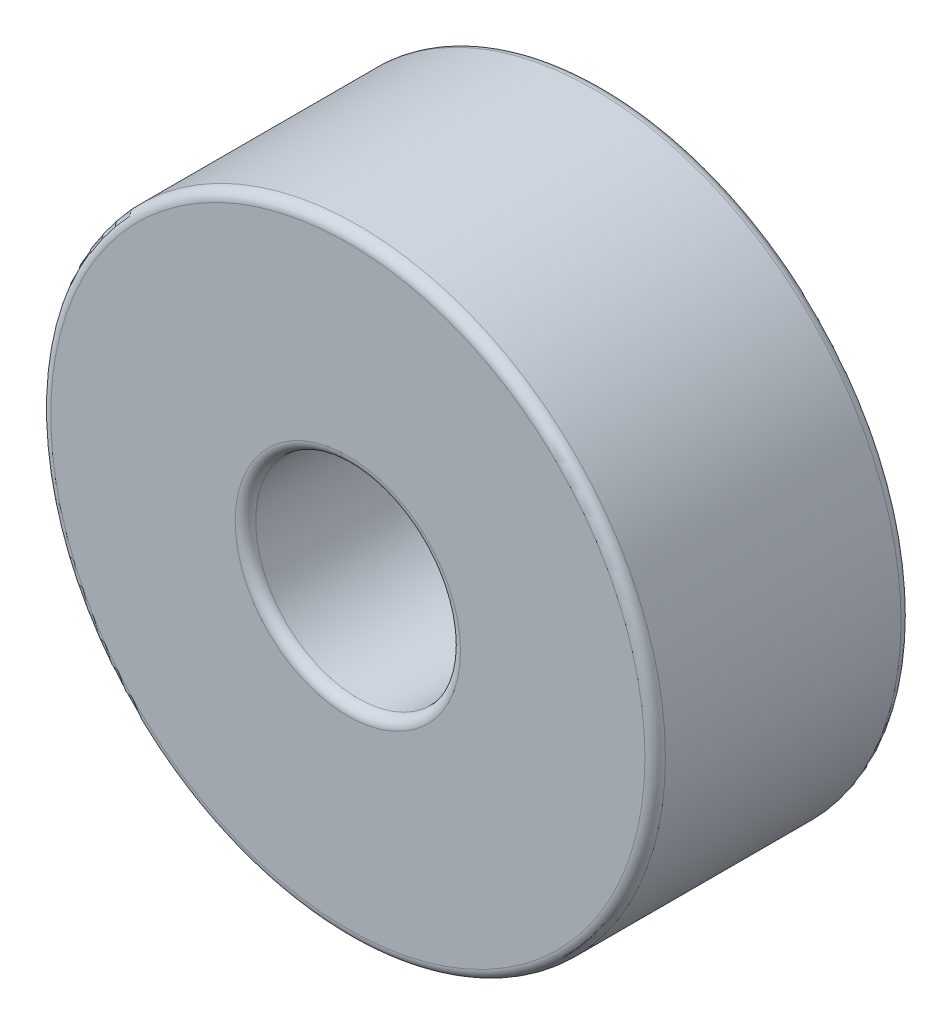
from build123d import *

# Parameters (mm, degrees)
SKETCH1_R           = 3
SKETCH1_R_2         = 1
BOSS_EXTRUDE1_DEPTH = 2.5
FILLET1_R           = 0.1
FILLET2_R           = 0.1


with BuildPart() as part:
    # Sketch1 → Boss-Extrude1 (new body)
    with BuildSketch(Plane.XY):
        Circle(SKETCH1_R)
        Circle(SKETCH1_R_2, mode=Mode.SUBTRACT)
    extrude(amount=BOSS_EXTRUDE1_DEPTH)

    # Fillet1
    fillet1_edges = [part.edges().sort_by_distance(p)[0] for p in [
        (-3, 0, 2.5),
    ]]
    fillet(fillet1_edges, radius=FILLET1_R)

    # Fillet2
    fillet2_edges = [part.edges().sort_by_distance(p)[0] for p in [
        (-3, 0, 0),
        (-1, 0, 0),
        (-1, 0, 2.5),
    ]]
    fillet(fillet2_edges, radius=FILLET2_R)


solid = part.part
